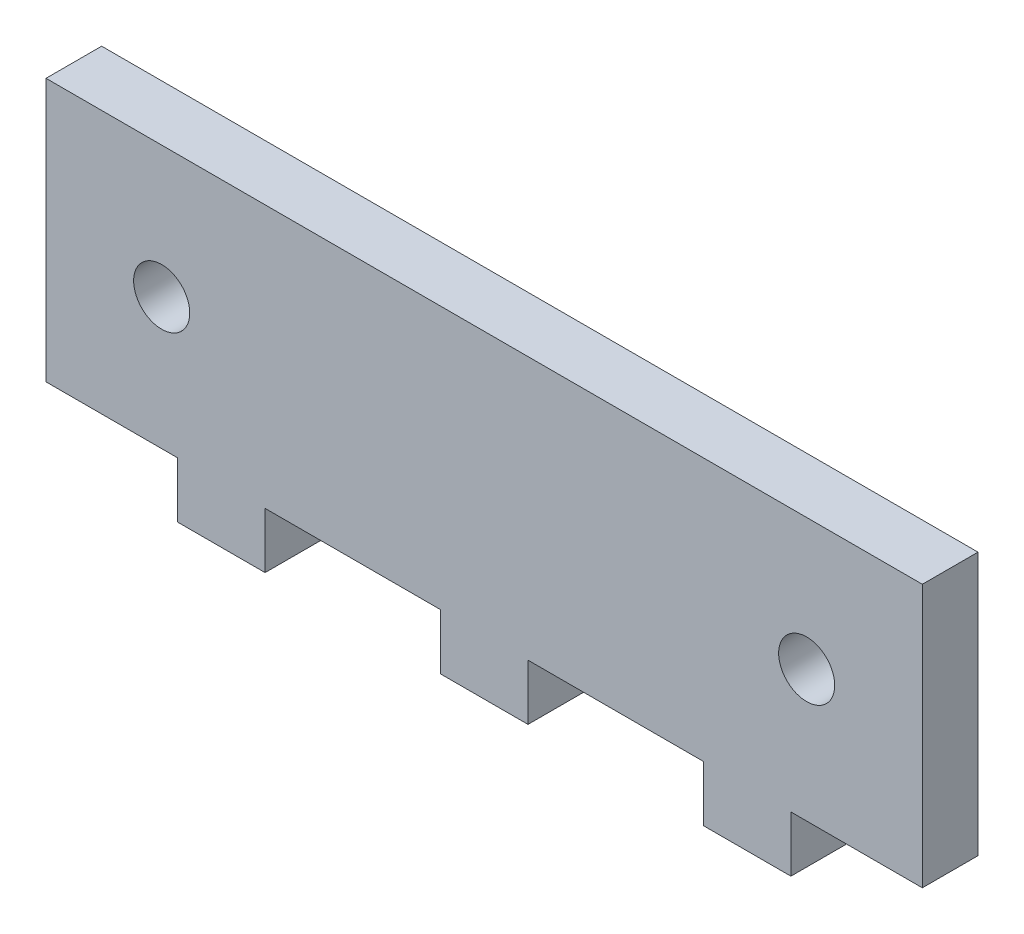
from build123d import *

# Parameters (mm, degrees)
BOSS_EXTRUDE1_DEPTH = 3.175
SKETCH2_R           = 1.6
CUT_EXTRUDE1_DEPTH  = 3.175


with BuildPart() as part:
    # Sketch1 → Boss-Extrude1 (new body)
    with BuildSketch(Plane.XY):
        Polygon((25, 7.5), (-25, 7.5), (-25, -7.5), (-17.5, -7.5), (-17.5, -10.675), (-12.5, -10.675), (-12.5, -7.5), (-2.5, -7.5), (-2.5, -10.675), (2.5, -10.675), (2.5, -7.5), (12.5, -7.5), (12.5, -10.675), (17.5, -10.675), (17.5, -7.5), (25, -7.5), align=None)
    extrude(amount=BOSS_EXTRUDE1_DEPTH)

    # Sketch2 → Cut-Extrude1 (cut)
    with BuildSketch(Plane.XY.offset(3.175)):
        with Locations((-18.4, 0)):
            Circle(SKETCH2_R)
        with Locations((18.4, 0)):
            Circle(SKETCH2_R)
    extrude(amount=-CUT_EXTRUDE1_DEPTH, mode=Mode.SUBTRACT)


solid = part.part
